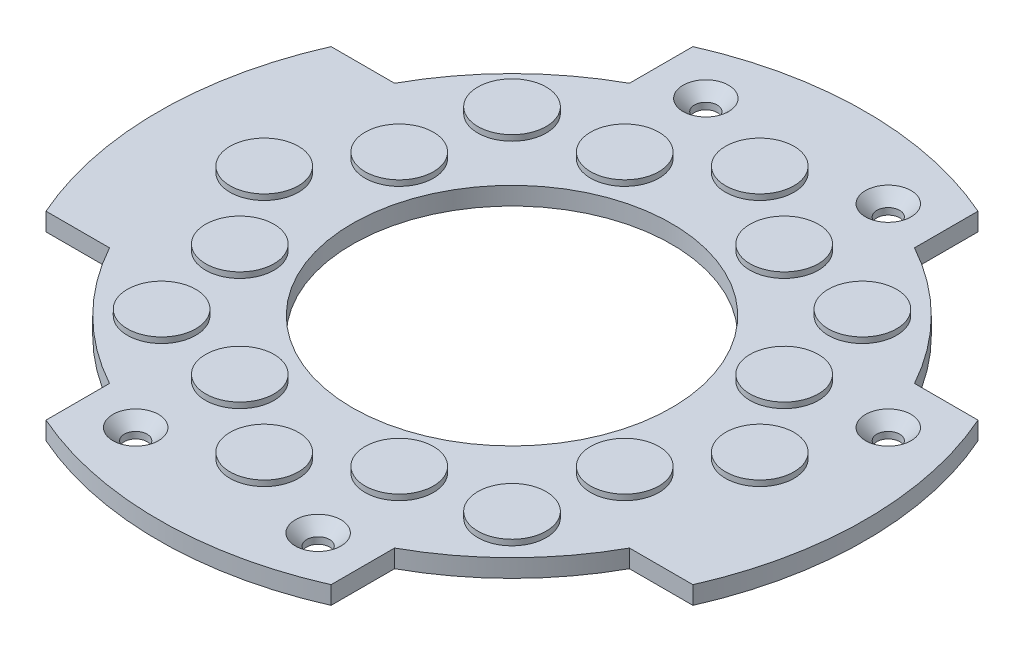
from build123d import *

# Parameters (mm, degrees)
SKETCH1_R           = 7
BOSS_EXTRUDE1_DEPTH = 0.7874
SKETCH2_R           = 1.5
BOSS_EXTRUDE2_DEPTH = 0.25
SKETCH3_R           = 0.5
CUT_EXTRUDE1_DEPTH  = 1.7874
CHAMFER1_SIZE       = 0.5


with BuildPart() as part:
    # Sketch1 → Boss-Extrude1 (new body)
    with BuildSketch(Plane(origin=(0, 0, 0), x_dir=(1, 0, 0), z_dir=(0, 1, 0))):
        with BuildLine():
            Line((-6.25, 14.184057953), (-6.25, 11.399013115))
            ThreePointArc((-6.25, 11.399013115), (-9.192388155, 9.192388155), (-11.399013115, 6.25))
            Line((-11.399013115, 6.25), (-14.184057953, 6.25))
            ThreePointArc((-14.184057953, 6.25), (-15.5, 0), (-14.184057953, -6.25))
            Line((-14.184057953, -6.25), (-11.399013115, -6.25))
            ThreePointArc((-11.399013115, -6.25), (-9.192388155, -9.192388155), (-6.25, -11.399013115))
            Line((-6.25, -11.399013115), (-6.25, -14.184057953))
            ThreePointArc((-6.25, -14.184057953), (0, -15.5), (6.25, -14.184057953))
            Line((6.25, -14.184057953), (6.25, -11.399013115))
            ThreePointArc((6.25, -11.399013115), (9.192388155, -9.192388155), (11.399013115, -6.25))
            Line((11.399013115, -6.25), (14.184057953, -6.25))
            ThreePointArc((14.184057953, -6.25), (15.5, 0), (14.184057953, 6.25))
            Line((14.184057953, 6.25), (11.399013115, 6.25))
            ThreePointArc((11.399013115, 6.25), (9.192388155, 9.192388155), (6.25, 11.399013115))
            Line((6.25, 11.399013115), (6.25, 14.184057953))
            ThreePointArc((6.25, 14.184057953), (0, 15.5), (-6.25, 14.184057953))
        make_face()
        Circle(SKETCH1_R, mode=Mode.SUBTRACT)
    extrude(amount=BOSS_EXTRUDE1_DEPTH)

    # Sketch2 → Boss-Extrude2 (add)
    with BuildSketch(Plane(origin=(0, 0.7874, 0), x_dir=(1, 0, 0), z_dir=(0, 1, 0))):
        with Locations((0, 10.865)):
            Circle(SKETCH2_R)
        with Locations((-3.495813155, 8.439639529)):
            Circle(SKETCH2_R)
        with Locations((-10.865, 0)):
            Circle(SKETCH2_R)
        with Locations((-8.439639529, 3.495813155)):
            Circle(SKETCH2_R)
        with Locations((-7.682715178, 7.682715178)):
            Circle(SKETCH2_R)
        with Locations((0, -10.865)):
            Circle(SKETCH2_R)
        with Locations((-3.495813155, -8.439639529)):
            Circle(SKETCH2_R)
        with Locations((-7.682715178, -7.682715178)):
            Circle(SKETCH2_R)
        with Locations((-8.439639529, -3.495813155)):
            Circle(SKETCH2_R)
        with Locations((3.495813155, 8.439639529)):
            Circle(SKETCH2_R)
        with Locations((7.682715178, 7.682715178)):
            Circle(SKETCH2_R)
        with Locations((8.439639529, 3.495813155)):
            Circle(SKETCH2_R)
        with Locations((10.865, 0)):
            Circle(SKETCH2_R)
        with Locations((8.439639529, -3.495813155)):
            Circle(SKETCH2_R)
        with Locations((7.682715178, -7.682715178)):
            Circle(SKETCH2_R)
        with Locations((3.495813155, -8.439639529)):
            Circle(SKETCH2_R)
    extrude(amount=BOSS_EXTRUDE2_DEPTH)

    # Sketch3 → Cut-Extrude1 (cut, through all)
    with BuildSketch(Plane(origin=(0, 0.7874, 0), x_dir=(1, 0, 0), z_dir=(0, 1, 0))):
        with Locations((-4, 12.5)):
            Circle(SKETCH3_R)
        with Locations((4, 12.5)):
            Circle(SKETCH3_R)
        with Locations((4, -12.5)):
            Circle(SKETCH3_R)
        with Locations((-4, -12.5)):
            Circle(SKETCH3_R)
        with Locations((12.5, 4)):
            Circle(SKETCH3_R)
    extrude(amount=-CUT_EXTRUDE1_DEPTH, mode=Mode.SUBTRACT)

    # Chamfer1
    chamfer1_edges = [part.edges().sort_by_distance(p)[0] for p in [
        (-4.5, 0.7874, -12.5),
        (3.5, 0.7874, -12.5),
        (3.5, 0.7874, 12.5),
        (-4.5, 0.7874, 12.5),
        (12, 0.7874, -4),
    ]]
    chamfer(chamfer1_edges, length=CHAMFER1_SIZE)


solid = part.part
